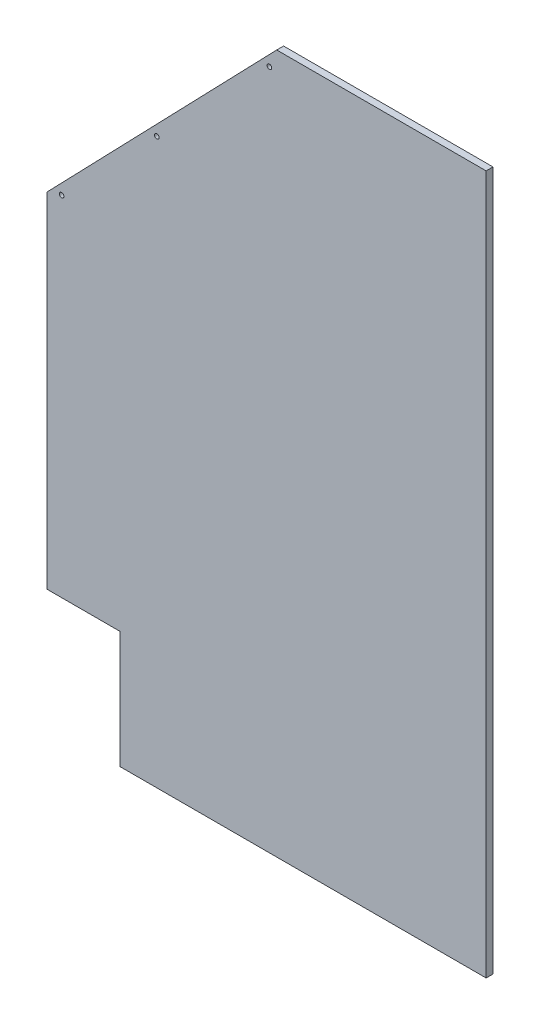
from build123d import *

# Parameters (mm, degrees)
BOSS_EXTRUDE1_DEPTH            = 11.90625
F_5_16_0_3125_DIAMETER_HOLE1_D = 7.9375
SKETCH4_W                      = 635
SKETCH4_H                      = 1212.85
CUT_EXTRUDE1_DEPTH             = 12.90625


with BuildPart() as part:
    # Sketch1 → Boss-Extrude1 (new body)
    with BuildSketch(Plane.XY):
        Polygon((1068.467396061, -524.104266958), (941.467396061, -524.104266958), (941.467396061, -727.304266958), (-201.532603939, -727.304266958), (-201.532603939, -524.104266958), (-328.532603939, -524.104266958), (-328.532603939, 72.795733042), (70.055437863, 485.545733042), (669.87935426, 485.545733042), (1068.467396061, 72.795733042), align=None)
    extrude(amount=BOSS_EXTRUDE1_DEPTH)

    # 5/16 (0.3125) Diameter Hole1 (through all)
    with Locations(Plane.XY.offset(11.90625)):
        with Locations((-303.132603939, 80.815834959), (-138.032603939, 251.781889765), (57.355437863, 454.112130003), (682.57935426, 454.112130003), (877.967396061, 251.781889765), (1043.067396061, 80.815834959)):
            Hole(F_5_16_0_3125_DIAMETER_HOLE1_D / 2)

    # Sketch4 → Cut-Extrude1 (cut, through all)
    with BuildSketch(Plane.XY.offset(11.90625)):
        with Locations((750.967396061, -120.879266958)):
            Rectangle(SKETCH4_W, SKETCH4_H)
    extrude(amount=-CUT_EXTRUDE1_DEPTH, mode=Mode.SUBTRACT)


solid = part.part
